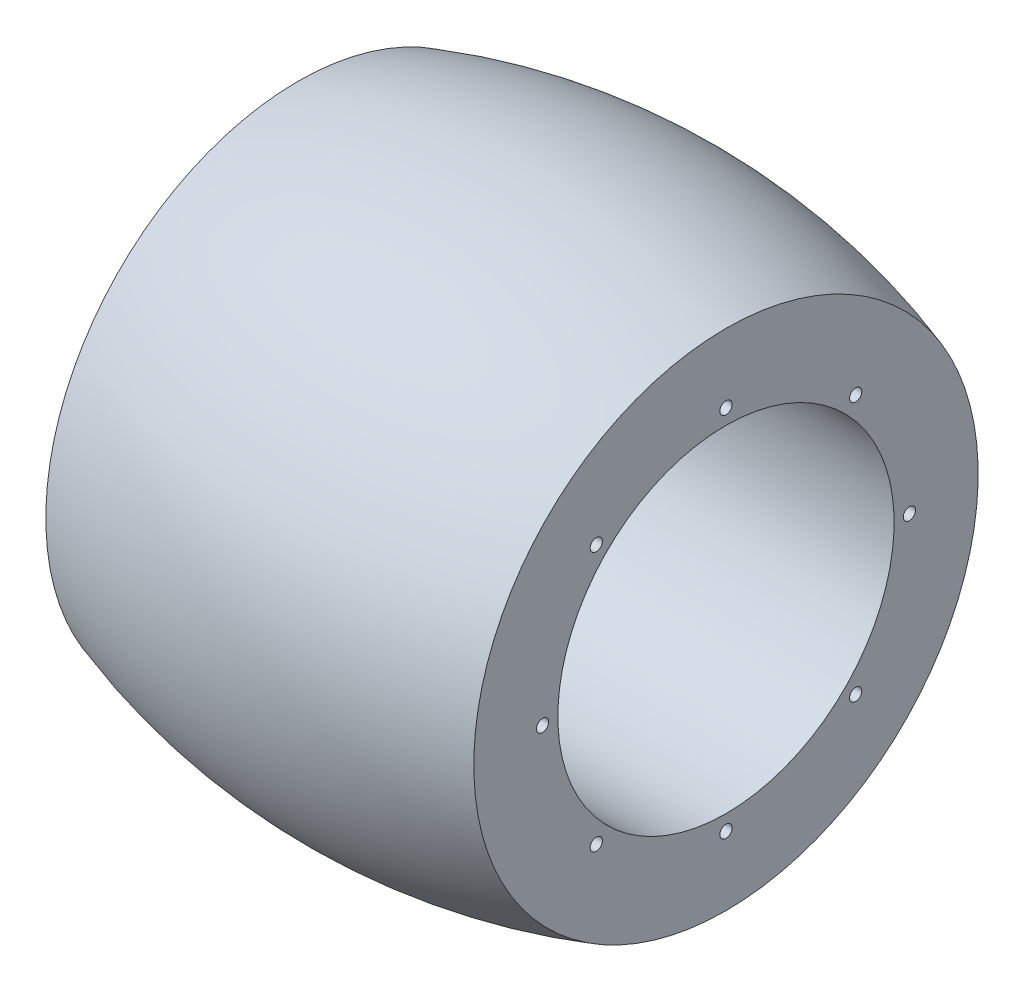
from build123d import *

# Parameters (mm, degrees)
FORMSENKUNG_F_R_M3_SENKSCHRAUBE_MIT_INNE_D           = 1.6
FORMSENKUNG_F_R_M3_SENKSCHRAUBE_MIT_INNE_DEPTH       = 12.5
FORMSENKUNG_F_R_M3_SENKSCHRAUBE_MIT_INNE_CSINK_D     = 3.75
FORMSENKUNG_F_R_M3_SENKSCHRAUBE_MIT_INNE_CSINK_ANGLE = 90
FORMSENKUNG_F_R_M3_SENKSCHRAUBE_MIT_INNE_TIP         = 0.480688495


with BuildPart() as part:
    # Skizze1 → Rotation1 (revolve)
    with BuildSketch(Plane.XY):
        with BuildLine():
            Line((28, 22), (28, 33))
            ThreePointArc((28, 33), (0, 37.5), (-28, 33))
            Line((-28, 33), (-28, 22))
            Line((-28, 22), (28, 22))
        make_face()
    revolve(axis=Axis((0, 0, 0), (-1, 0, 0)))

    # Formsenkung für M3 Senkschraube mit Innensechskant2
    with Locations(Plane(origin=(32.5, -4.747521164, 0), x_dir=(0, 0, 1), z_dir=(1, 0, 0))):
        with Locations((0, -28.747521164), (16.970562748, -21.718083913), (24, -4.747521164), (16.970562748, 12.223041584), (0, 19.252478836), (-16.970562748, 12.223041584), (-24, -4.747521164), (-16.970562748, -21.718083913), (0, -4.747521164)):
            CounterSinkHole(FORMSENKUNG_F_R_M3_SENKSCHRAUBE_MIT_INNE_D / 2, FORMSENKUNG_F_R_M3_SENKSCHRAUBE_MIT_INNE_CSINK_D / 2, depth=FORMSENKUNG_F_R_M3_SENKSCHRAUBE_MIT_INNE_DEPTH, counter_sink_angle=FORMSENKUNG_F_R_M3_SENKSCHRAUBE_MIT_INNE_CSINK_ANGLE)
            with Locations((0, 0, -(FORMSENKUNG_F_R_M3_SENKSCHRAUBE_MIT_INNE_DEPTH + FORMSENKUNG_F_R_M3_SENKSCHRAUBE_MIT_INNE_TIP / 2))):  # 118° drill point
                Cone(0, FORMSENKUNG_F_R_M3_SENKSCHRAUBE_MIT_INNE_D / 2, FORMSENKUNG_F_R_M3_SENKSCHRAUBE_MIT_INNE_TIP, mode=Mode.SUBTRACT)


solid = part.part
